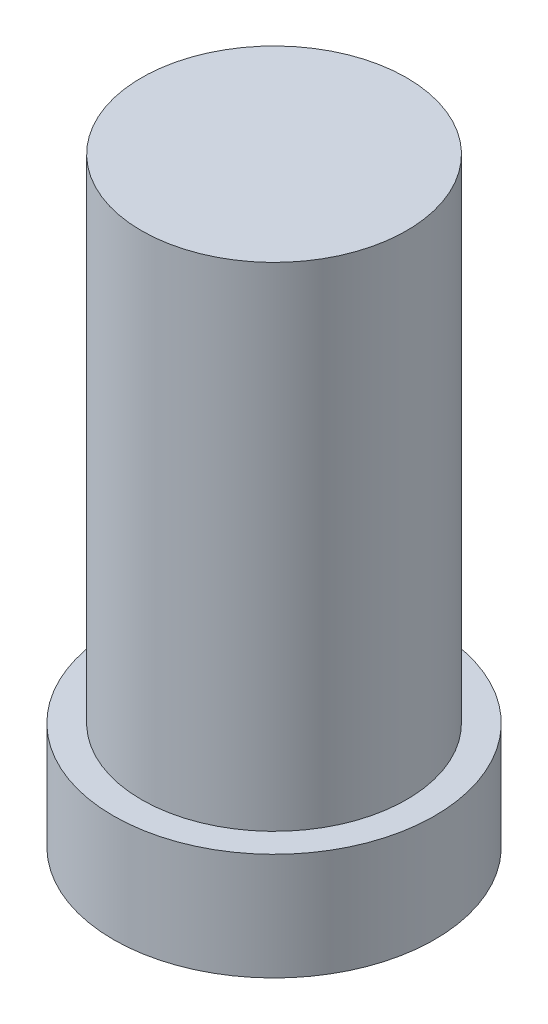
from build123d import *

# Parameters (mm, degrees)
SKETCH3_R           = 3
BOSS_EXTRUDE1_DEPTH = 2
SKETCH4_R           = 2.475
BOSS_EXTRUDE2_DEPTH = 11.2


with BuildPart() as part:
    # Sketch3 → Boss-Extrude1 (new body)
    with BuildSketch(Plane(origin=(0, 0, 0), x_dir=(1, 0, 0), z_dir=(0, 1, 0))):
        Circle(SKETCH3_R)
    extrude(amount=BOSS_EXTRUDE1_DEPTH)

    # Sketch4 → Boss-Extrude2 (add)
    with BuildSketch(Plane(origin=(0, 0, 0), x_dir=(1, 0, 0), z_dir=(0, 1, 0))):
        Circle(SKETCH4_R)
    extrude(amount=BOSS_EXTRUDE2_DEPTH)


solid = part.part
